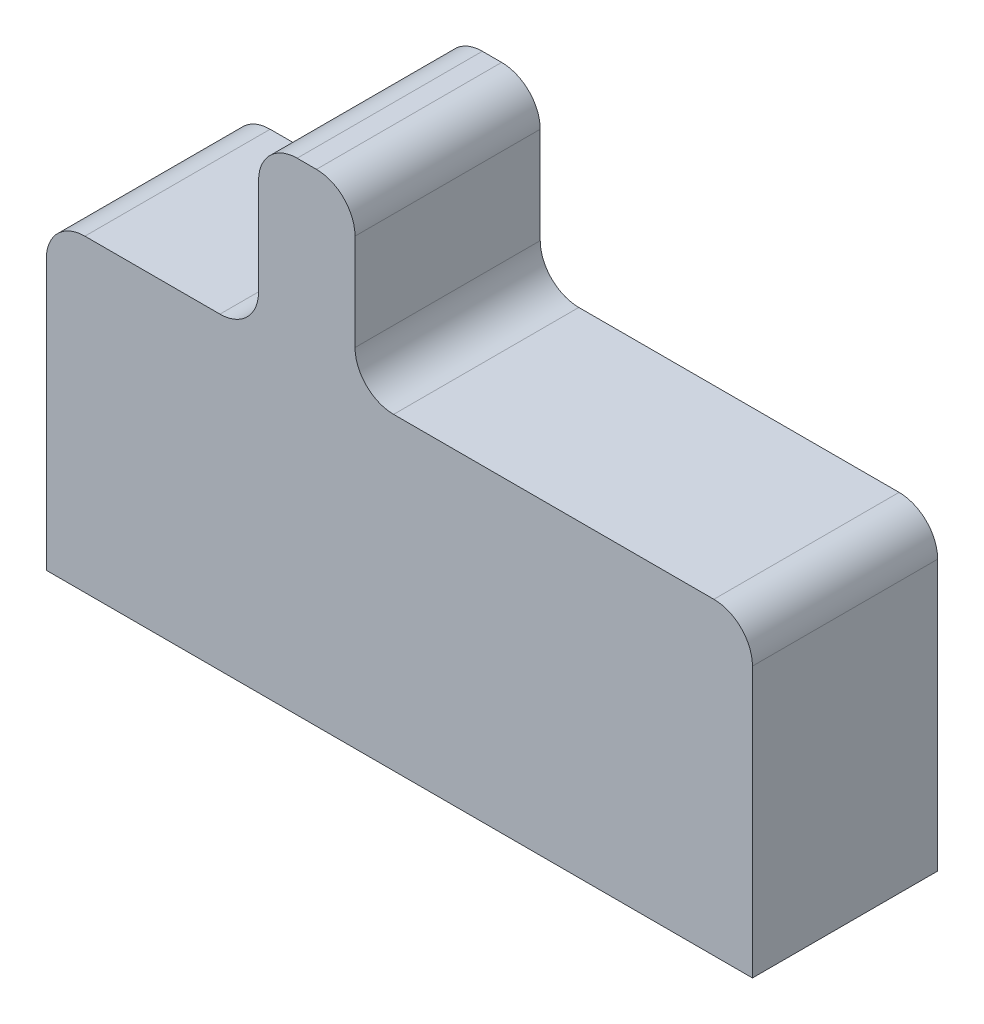
from build123d import *

# Parameters (mm, degrees)
BOSS_EXTRUDE1_DEPTH = 0.96
FILLET1_R           = 0.2


with BuildPart() as part:
    # Sketch1 → Boss-Extrude1 (new body)
    with BuildSketch(Plane.XY):
        Polygon((-0.73, 0.8), (-0.73, 1.7), (-0.23, 1.7), (-0.23, 0.8), (1.83, 0.8), (1.83, -0.8), (-1.83, -0.8), (-1.83, 0.8), align=None)
    extrude(amount=BOSS_EXTRUDE1_DEPTH)

    # Fillet1
    fillet1_edges = [part.edges().sort_by_distance(p)[0] for p in [
        (-1.83, 0.8, 0.48),
        (-0.73, 0.8, 0.48),
        (-0.73, 1.7, 0.48),
        (-0.23, 1.7, 0.48),
        (-0.23, 0.8, 0.48),
        (1.83, 0.8, 0.48),
    ]]
    fillet(fillet1_edges, radius=FILLET1_R)


solid = part.part
